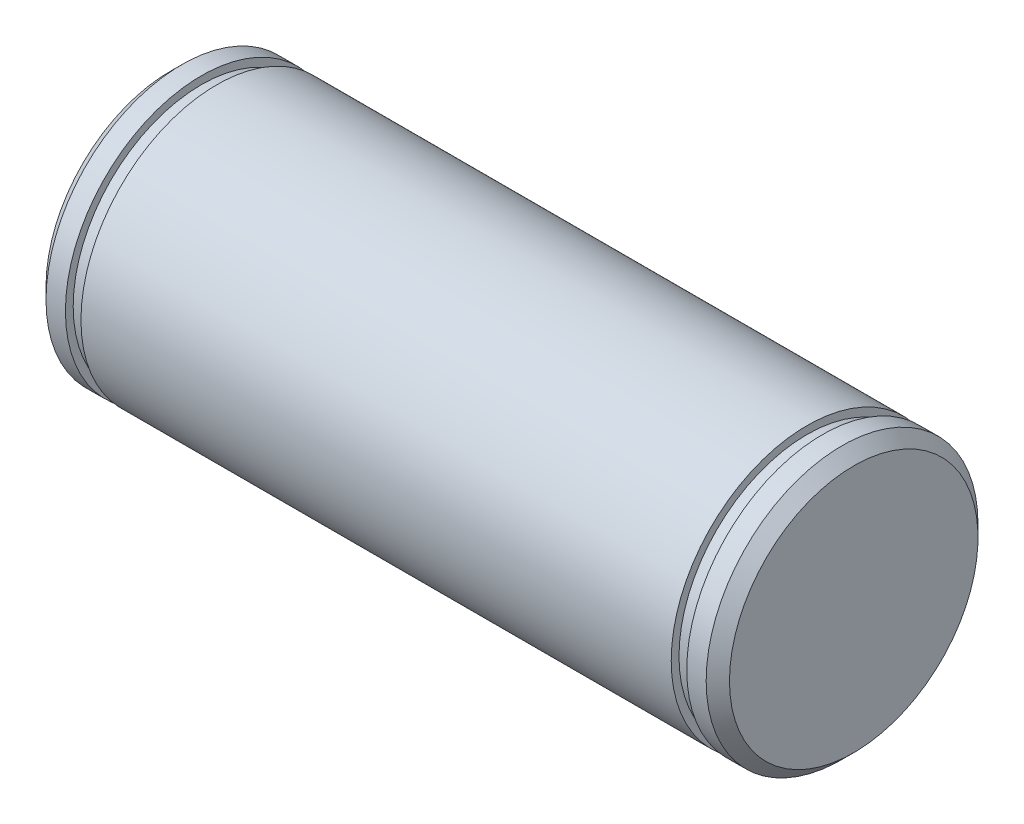
from build123d import *


with BuildPart() as part:
    # Sketch1 → Revolve1 (revolve)
    with BuildSketch(Plane.XY, mode=Mode.PRIVATE) as revolve1_sk:
        Polygon((4, 16.5), (4, 17.5), (1.5, 17.5), (0, 16), (0, 0), (88, 0), (88, 16), (86.5, 17.5), (84, 17.5), (84, 16.5), (82, 16.5), (82, 17.5), (6, 17.5), (6, 16.5), align=None)
    revolve(revolve1_sk.sketch.rotate(Axis((-2, 0, 0), (1, 0, 0)), 90), axis=Axis((-2, 0, 0), (1, 0, 0)))


solid = part.part
